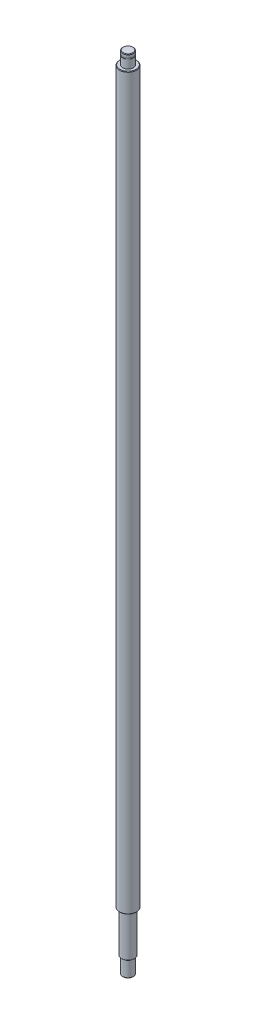
from build123d import *

# Parameters (mm, degrees)
CHAMFER_1_SIZE = 0.5


with BuildPart() as part:
    # Эскиз1 → Повернуть1 (revolve)
    with BuildSketch(Plane.XY):
        Polygon((0, 0), (-5, 0), (-5, 15), (-6, 15), (-6, 54), (-8, 54), (-8, 738), (-5, 738), (-5, 746), (-4.8, 746), (-4.8, 747.15), (-5, 747.15), (-5, 750), (0, 750), align=None)
    revolve(axis=Axis((0, 750, 0), (0, -1, 0)))

    # Фаска1
    chamfer_1_edges = [part.edges().sort_by_distance(p)[0] for p in [
        (8, 738, 0),
        (8, 54, 0),
        (6, 15, 0),
        (5, 0, 0),
        (5, 750, 0),
    ]]
    chamfer(chamfer_1_edges, length=CHAMFER_1_SIZE)


solid = part.part
